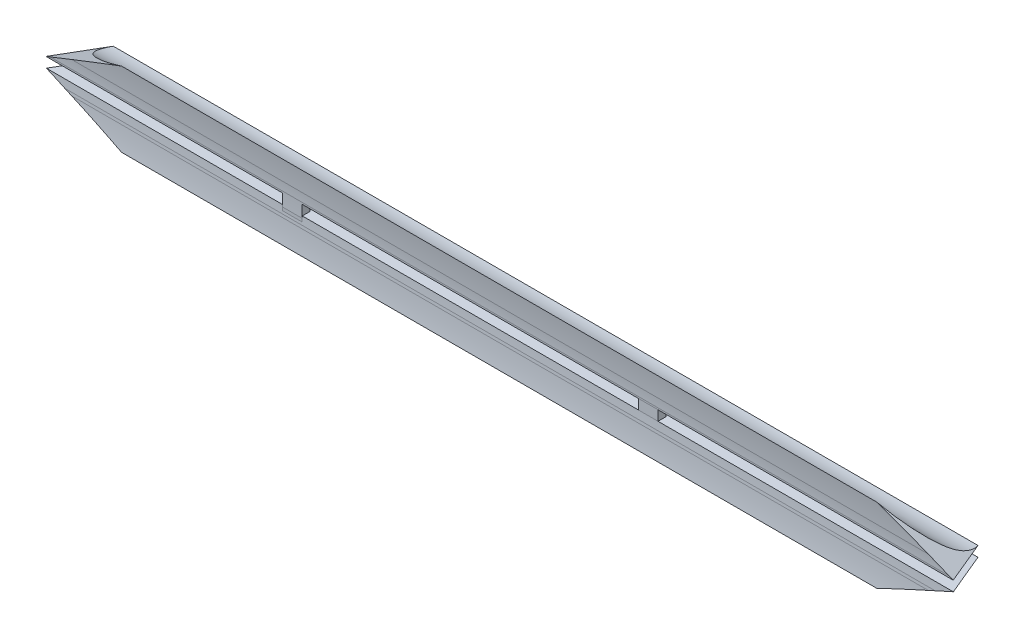
from build123d import *

# Parameters (mm, degrees)
BOSS_EXTRUDE1_DEPTH      = 3.302
CHAMFER1_SIZE            = 1.27
CHAMFER1_SIZE2           = 2.723523789
CHAMFER1_PART_2_SIZE     = 1.27
CHAMFER1_PART_2_SIZE2    = 2.723523789
CHAMFER1_PART_3_SIZE     = 1.27
CHAMFER1_PART_3_SIZE2    = 2.723523789
BOSS_EXTRUDE2_DEPTH      = 304.8
LEADING_SIDE_DEPTH       = 8.679028657
LEADING_SIDE_DEPTH_BACK  = 277.442337519
TRAILING_SIDE_DEPTH      = 254
TRAILING_SIDE_DEPTH_BACK = 27.94
SKETCH9_W                = 305.493611557
SKETCH9_H                = 3.302
CUT_EXTRUDE1_DEPTH       = 9.89
CUT_EXTRUDE1_DEPTH_BACK  = 143.24
BOSS_EXTRUDE3_REACH      = 16.738
SKETCH10_W               = 6.35
SKETCH10_H               = 2.54
BOSS_EXTRUDE4_REACH      = 16.738
SKETCH11_W               = 6.35
SKETCH11_H               = 2.54
SKETCH12_R               = 78.609915156
CUT_EXTRUDE3_DEPTH       = 302.817401479


with BuildPart() as part:
    # Sketch1 → Boss-Extrude1 (new body)
    with BuildSketch(Plane(origin=(0, 0, 0), x_dir=(1, 0, 0), z_dir=(0, 1, 0))):
        Polygon((0, 0), (88.9, 142.24), (241.3, 142.24), (304.8, 0), (151.13, 0), (151.13, -8.89), (113.03, -8.89), (113.03, 0), align=None)
    extrude(amount=BOSS_EXTRUDE1_DEPTH)

    # Chamfer1
    chamfer1_edges = [part.edges().sort_by_distance(p)[0] for p in [
        (273.05, 3.302, -71.12),
        (273.05, 0, -71.12),
    ]]
    chamfer1_side = [part.faces().sort_by_distance(p)[0] for p in [
        (273.05, 1.651, -71.12),
    ]]
    chamfer(chamfer1_edges, length=CHAMFER1_SIZE, length2=CHAMFER1_SIZE2, reference=chamfer1_side[0])

    # Chamfer1 part 2
    chamfer1_part_2_edges = [part.edges().sort_by_distance(p)[0] for p in [
        (165.1, 3.302, -142.24),
        (165.1, 0, -142.24),
    ]]
    chamfer1_part_2_side = [part.faces().sort_by_distance(p)[0] for p in [
        (165.1, 1.651, -142.24),
    ]]
    chamfer(chamfer1_part_2_edges, length=CHAMFER1_PART_2_SIZE, length2=CHAMFER1_PART_2_SIZE2, reference=chamfer1_part_2_side[0])

    # Chamfer1 part 3
    chamfer1_part_3_edges = [part.edges().sort_by_distance(p)[0] for p in [
        (44.45, 3.302, -71.12),
        (44.45, 0, -71.12),
    ]]
    chamfer1_part_3_side = [part.faces().sort_by_distance(p)[0] for p in [
        (44.45, 1.651, -71.12),
    ]]
    chamfer(chamfer1_part_3_edges, length=CHAMFER1_PART_3_SIZE, length2=CHAMFER1_PART_3_SIZE2, reference=chamfer1_part_3_side[0])

    # Sketch2 → Boss-Extrude2 (add)
    with BuildSketch(Plane(origin=(0, 0, 0), x_dir=(0, 0, -1), z_dir=(1, 0, 0))):
        with BuildLine():
            Line((0, 3.302), (0.193860014, 3.302))
            ThreePointArc((0.193860014, 3.302), (0.095787095, 7.86512735), (-0.267795454, 12.414803957))
            add(Edge.make_bspline(
                [(-0.267795454, 12.414803957), (-0.672599921, 13.160197553), (-1.025420185, 13.935695512), (-1.319449565, 14.73847888)],
                knots=[0.873023633, 0.873023633, 0.873023633, 0.873023633, 1, 1, 1, 1], degree=3))
            add(Edge.make_bspline(
                [(-1.319449565, 14.73847888), (-0.620020797, 10.967807625), (0.041688756, 7.150478935), (0, 3.302)],
                knots=[0, 0, 0, 0, 1, 1, 1, 1], degree=3))
        make_face()
        with BuildLine():
            ThreePointArc((-0.267795454, 12.414803957), (0.095787095, 7.86512735), (0.193860014, 3.302))
            Line((0.193860014, 3.302), (13.71197658, 3.302))
            add(Edge.make_bspline(
                [(13.71197658, 3.302), (11.020860037, 3.394720033), (7.304618249, 4.403456005), (2.735609274, 8.059966642), (0.759058851, 10.523988305), (-0.267795454, 12.414803957)],
                knots=[0, 0, 0, 0, 0.405371861, 0.550926818, 0.873023633, 0.873023633, 0.873023633, 0.873023633], degree=3))
        make_face()
        with BuildLine():
            Line((13.71197658, 0), (0.099005708, 0))
            ThreePointArc((0.099005708, 0), (0.027136855, -1.243216756), (-0.064479677, -2.485134404))
            add(Edge.make_bspline(
                [(-0.706755386, -7.960561287), (-0.413166837, -6.144437691), (-0.174809494, -4.318730126), (-0.064479677, -2.485134404)],
                knots=[0.306156166, 0.306156166, 0.306156166, 0.306156166, 0.784361963, 0.784361963, 0.784361963, 0.784361963], degree=3))
            ThreePointArc((-0.706755386, -7.960561287), (-0.993529388, -9.701970199), (-1.319449565, -11.43647888))
            add(Edge.make_bspline(
                [(13.71197658, 0), (11.020860037, -0.092720033), (7.304618249, -1.101456005), (2.071072669, -5.289785507), (-0.279565435, -8.597301093), (-1.319449565, -11.43647888)],
                knots=[0, 0, 0, 0, 0.405371861, 0.550926818, 1, 1, 1, 1], degree=3))
        make_face()
    extrude(amount=BOSS_EXTRUDE2_DEPTH)

    # Sketch4 → Leading Side (cut, two sides)
    with BuildSketch(Plane(origin=(0, 0, 0), x_dir=(0, -1, 0), z_dir=(-0.503864435, 0, 0.863782745))) as leading_side_sk:
        Polygon((0, -7.461077899), (0, 8.059009466), (11.69047888, 33.129322328), (11.69047888, -6.284577832), align=None)
        Polygon((-14.99247888, 33.129322328), (-14.99247888, -6.284577832), (-3.302, -7.461077899), (-3.302, 8.059009466), align=None)
    extrude(amount=LEADING_SIDE_DEPTH, mode=Mode.SUBTRACT)
    extrude(leading_side_sk.sketch, amount=-LEADING_SIDE_DEPTH_BACK, mode=Mode.SUBTRACT)

    # Sketch6 → Trailing Side (cut, two sides)
    with BuildSketch(Plane(origin=(45.089267536, 0, 108.213523637), x_dir=(0, -1, 0), z_dir=(-0.38461756, 0, -0.923076016))) as trailing_side_sk:
        Polygon((0, -286.627436809), (0, -278.59888787), (11.43647888, -254.073279765), (11.43647888, -287.965550571), align=None)
        Polygon((-14.73847888, -254.073279765), (-14.73847888, -287.965550571), (-3.302, -286.627436809), (-3.302, -278.600404574), align=None)
    extrude(amount=TRAILING_SIDE_DEPTH, mode=Mode.SUBTRACT)
    extrude(trailing_side_sk.sketch, amount=-TRAILING_SIDE_DEPTH_BACK, mode=Mode.SUBTRACT)

    # Sketch9 → Cut-Extrude1 (cut, two sides)
    with BuildSketch(Plane.XY) as cut_extrude1_sk:
        with Locations((152.259463857, 1.651)):
            Rectangle(SKETCH9_W, SKETCH9_H)
    extrude(amount=CUT_EXTRUDE1_DEPTH, mode=Mode.SUBTRACT)
    extrude(cut_extrude1_sk.sketch, amount=-CUT_EXTRUDE1_DEPTH_BACK, mode=Mode.SUBTRACT)

    # Sketch10 → Boss-Extrude3 (add, up to next)
    with BuildSketch(Plane(origin=(0, 0, 0), x_dir=(1, 0, 0), z_dir=(0, 1, 0)), mode=Mode.PRIVATE) as boss_extrude3_sk1:
        with Locations((203.392401379, 1.369005708)):
            Rectangle(SKETCH10_W, SKETCH10_H)
    boss_extrude3_tool1 = extrude(boss_extrude3_sk1.sketch, amount=BOSS_EXTRUDE3_REACH, mode=Mode.PRIVATE) - part.part
    add(boss_extrude3_tool1.solids().sort_by_distance((203.392401, 0, -1.369006))[0])

    # Sketch11 → Boss-Extrude4 (add, up to next)
    with BuildSketch(Plane.XZ.offset(-3.302), mode=Mode.PRIVATE) as boss_extrude4_sk1:
        with Locations((88.704903276, -1.27)):
            Rectangle(SKETCH11_W, SKETCH11_H)
    boss_extrude4_tool1 = extrude(boss_extrude4_sk1.sketch, amount=BOSS_EXTRUDE4_REACH, mode=Mode.PRIVATE) - part.part
    add(boss_extrude4_tool1.solids().sort_by_distance((88.704903, 3.302, -1.27))[0])

    # Sketch12 → Cut-Extrude3 (cut, through all)
    with BuildSketch(Plane(origin=(0, 0, 0), x_dir=(0, 0, -1), z_dir=(1, 0, 0))):
        with Locations((-78.577787481, 1.651)):
            Circle(SKETCH12_R)
    extrude(amount=CUT_EXTRUDE3_DEPTH, mode=Mode.SUBTRACT)


solid = part.part
